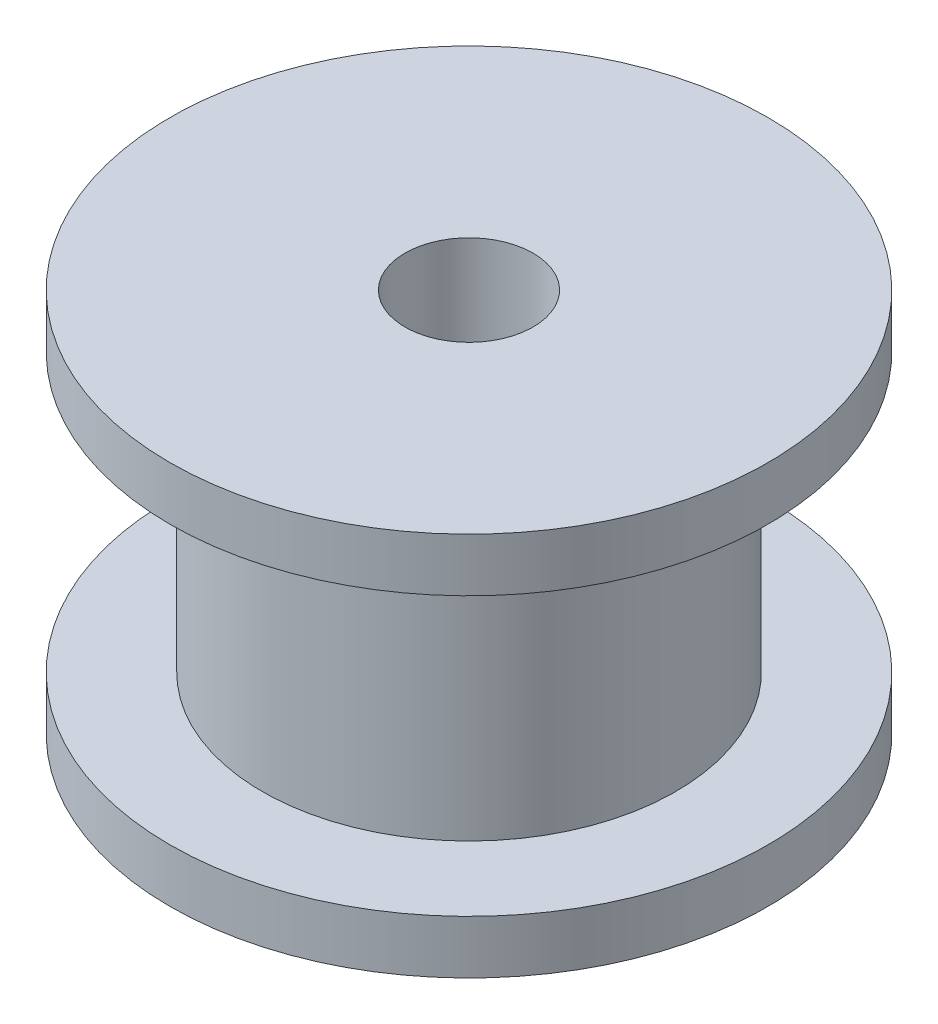
from build123d import *


with BuildPart() as part:
    # Esboço1 → Revolução1 (revolve)
    with BuildSketch(Plane.XY):
        Polygon((1.5, 9), (7, 9), (7, 7.75), (4.84, 7.75), (4.84, 1.25), (7, 1.25), (7, 0), (1.5, 0), align=None)
    revolve(axis=Axis((0, 0, 0), (0, 1, 0)))


solid = part.part
